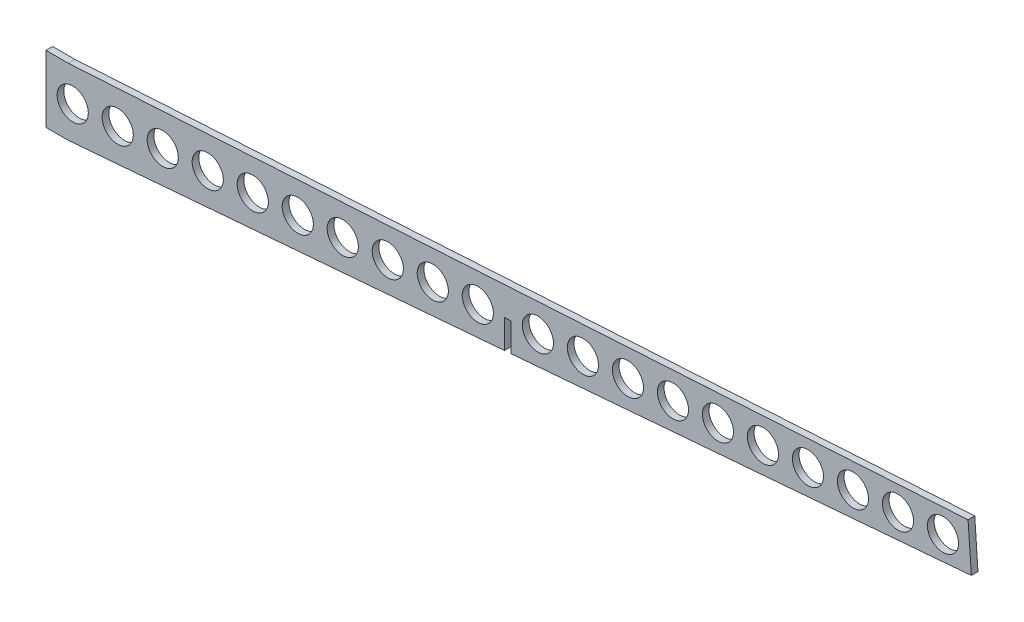
from build123d import *

# Parameters (mm, degrees)
BOSS_EXTRUDE1_DEPTH     = 3
SKETCH2_R               = 7
SKETCH2_W               = 3
SKETCH2_H               = 12.946630698
CUT_EXTRUDE1_DEPTH      = 1
CUT_EXTRUDE1_DEPTH_BACK = 4


with BuildPart() as part:
    # Sketch1 → Boss-Extrude1 (new body)
    with BuildSketch(Plane.XY):
        Polygon((-415, 0), (-415, 30), (-405, 30), (-0.732442974, 54.494049484), (0.732442974, 33.545204429), (-405, 0), align=None)
    extrude(amount=BOSS_EXTRUDE1_DEPTH)

    # Sketch2 → Cut-Extrude1 (cut, two sides)
    with BuildSketch(Plane.XY.offset(3)) as cut_extrude1_sk:
        with Locations((-403, 15.1433068)):
            Circle(SKETCH2_R)
        with Locations((-382.777777778, 16.592297775)):
            Circle(SKETCH2_R)
        with Locations((-362.555555556, 18.041288751)):
            Circle(SKETCH2_R)
        with Locations((-342.333333333, 19.490279727)):
            Circle(SKETCH2_R)
        with Locations((-322.111111111, 20.939270702)):
            Circle(SKETCH2_R)
        with Locations((-301.888888889, 22.388261678)):
            Circle(SKETCH2_R)
        with Locations((-281.666666667, 23.837252653)):
            Circle(SKETCH2_R)
        with Locations((-261.444444444, 25.286243629)):
            Circle(SKETCH2_R)
        with Locations((-241.222222222, 26.735234605)):
            Circle(SKETCH2_R)
        with Locations((-221, 28.18422558)):
            Circle(SKETCH2_R)
        with Locations((-194, 30.118867377)):
            Circle(SKETCH2_R)
        with Locations((-173.777777778, 31.567858353)):
            Circle(SKETCH2_R)
        with Locations((-153.555555556, 33.016849329)):
            Circle(SKETCH2_R)
        with Locations((-133.333333333, 34.465840304)):
            Circle(SKETCH2_R)
        with Locations((-113.111111111, 35.91483128)):
            Circle(SKETCH2_R)
        with Locations((-92.888888889, 37.363822255)):
            Circle(SKETCH2_R)
        with Locations((-72.666666667, 38.812813231)):
            Circle(SKETCH2_R)
        with Locations((-52.444444444, 40.261804207)):
            Circle(SKETCH2_R)
        with Locations((-32.222222222, 41.710795182)):
            Circle(SKETCH2_R)
        with Locations((-12, 43.159786158)):
            Circle(SKETCH2_R)
        with Locations((-207.5, 22.67823113)):
            Rectangle(SKETCH2_W, SKETCH2_H)
    extrude(amount=CUT_EXTRUDE1_DEPTH, mode=Mode.SUBTRACT)
    extrude(cut_extrude1_sk.sketch, amount=-CUT_EXTRUDE1_DEPTH_BACK, mode=Mode.SUBTRACT)


solid = part.part
